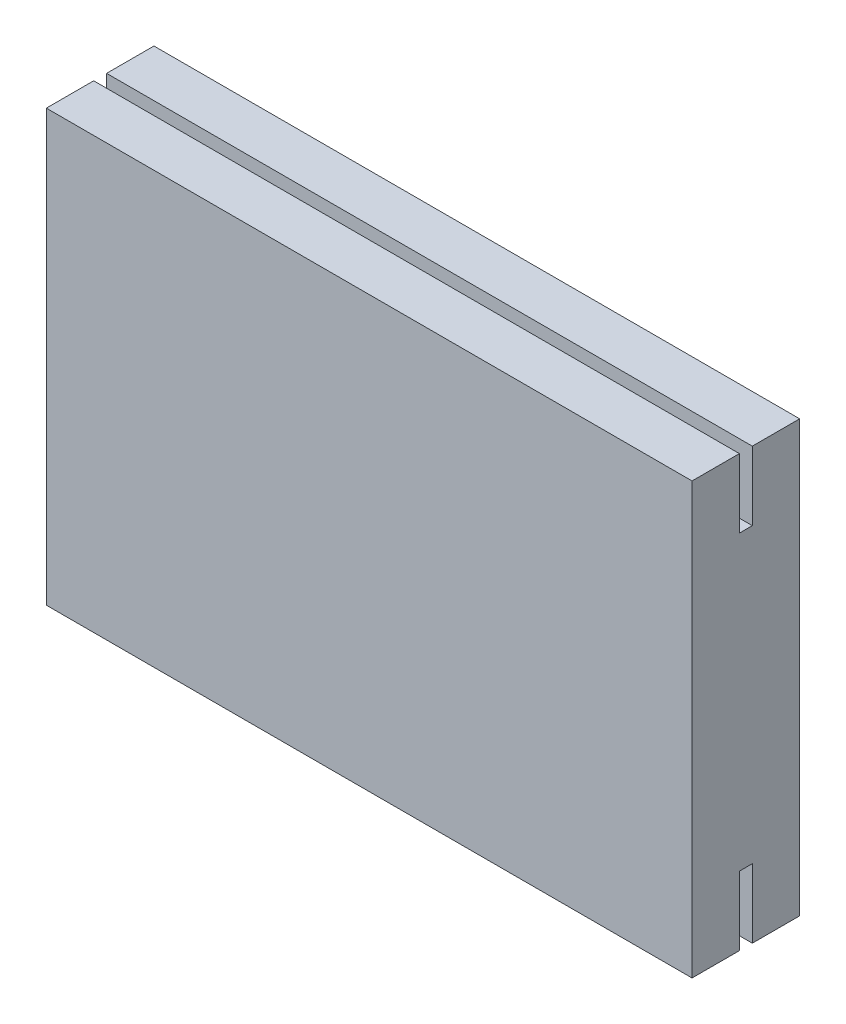
from build123d import *

# Parameters (mm, degrees)
SKETCH4_W           = 5
SKETCH4_H           = 20
BOSS_EXTRUDE2_DEPTH = 30
CUT_EXTRUDE3_DEPTH  = 31


with BuildPart() as part:
    # Sketch4 → Boss-Extrude2 (new body)
    with BuildSketch(Plane(origin=(0, 0, 0), x_dir=(0, 0, -1), z_dir=(1, 0, 0))):
        Rectangle(SKETCH4_W, SKETCH4_H)
    extrude(amount=BOSS_EXTRUDE2_DEPTH)

    # Sketch5 → Cut-Extrude3 (cut, through all)
    with BuildSketch(Plane(origin=(30, 0, 0), x_dir=(0, 0, -1), z_dir=(1, 0, 0))):
        Polygon((0.3, 6.8), (0.3, 10), (0, 10), (-0.3, 10), (-0.3, 6.8), align=None)
    cut_extrude3 = extrude(amount=-CUT_EXTRUDE3_DEPTH, mode=Mode.SUBTRACT)

    # Mirror3: Cut-Extrude3 across plane
    add(cut_extrude3.mirror(Plane.ZX), mode=Mode.SUBTRACT)


solid = part.part
